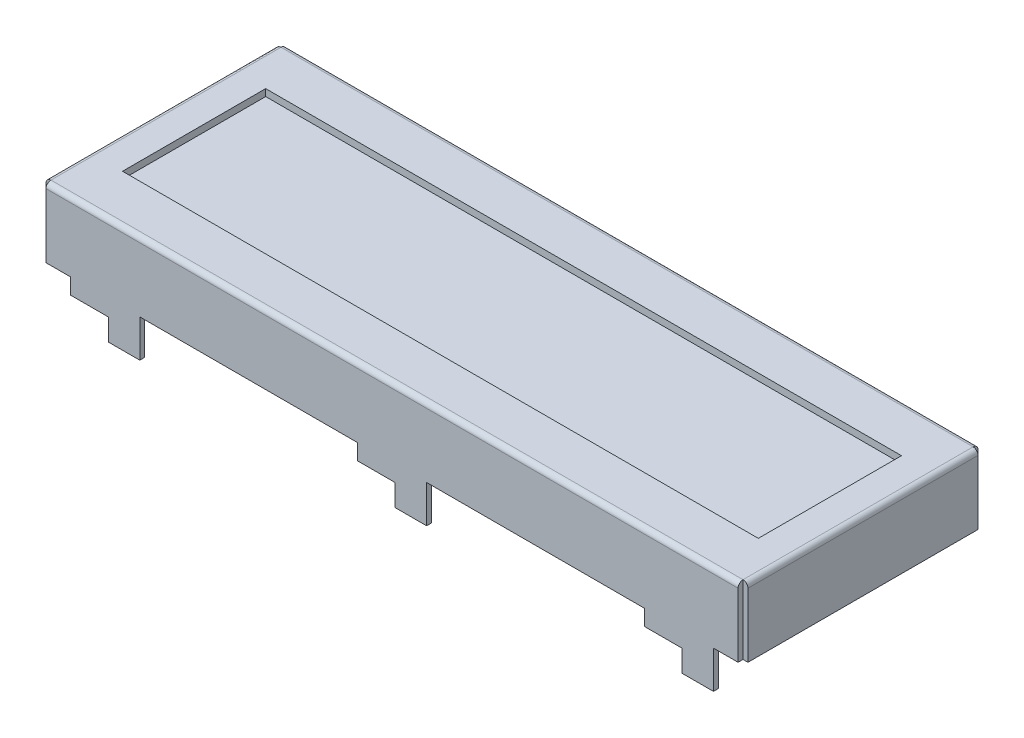
from build123d import *

# Parameters (mm, degrees)
ESQUISSE1_W             = 71.1
ESQUISSE1_H             = 24.3
BOSS_EXTRU_1_DEPTH      = 7
CONG_1_R                = 0.5
ESQUISSE2_W             = 1.653567917
ESQUISSE2_H             = 1.375254205
ESQUISSE2_W_2           = 1.332598991
ESQUISSE2_H_2           = 1.640495544
ESQUISSE2_W_3           = 1.790407611
ESQUISSE2_H_3           = 2.285395674
ENL_V_MAT_EXTRU_1_DEPTH = 7
ESQUISSE3_W             = 64.4
ESQUISSE3_H             = 14.5
ENL_V_MAT_EXTRU_2_DEPTH = 0.7
ESQUISSE4_W             = 7
ESQUISSE4_H             = 0.5
BOSS_EXTRU_2_DEPTH      = 1.6
BOSS_EXTRU_3_DEPTH      = 2.2


with BuildPart() as part:
    # Esquisse1 → Boss.-Extru.1 (new body)
    with BuildSketch(Plane(origin=(0, 0, 0), x_dir=(1, 0, 0), z_dir=(0, 1, 0))):
        with Locations((35.55, 12.15)):
            Rectangle(ESQUISSE1_W, ESQUISSE1_H)
    extrude(amount=BOSS_EXTRU_1_DEPTH)

    # Congé1
    cong_1_edges = [part.edges().sort_by_distance(p)[0] for p in [
        (71.1, 7, -12.15),
        (35.55, 7, -24.3),
        (0, 7, -12.15),
        (35.55, 7, 0),
    ]]
    fillet(cong_1_edges, radius=CONG_1_R)

    # Esquisse2 → Enlèv. mat.-Extru.1 (cut)
    with BuildSketch(Plane(origin=(0, 7, 0), x_dir=(1, 0, 0), z_dir=(0, 1, 0))):
        with Locations((-0.326783959, 24.487627102)):
            Rectangle(ESQUISSE2_W, ESQUISSE2_H)
        with Locations((-0.166299496, -0.320247772)):
            Rectangle(ESQUISSE2_W_2, ESQUISSE2_H_2)
        with Locations((71.495203806, -0.320247772)):
            Rectangle(ESQUISSE2_W_3, ESQUISSE2_H_2)
        with Locations((71.495203806, 24.942697837)):
            Rectangle(ESQUISSE2_W_3, ESQUISSE2_H_3)
    extrude(amount=-ENL_V_MAT_EXTRU_1_DEPTH, mode=Mode.SUBTRACT)

    # Esquisse3 → Enlèv. mat.-Extru.2 (cut)
    with BuildSketch(Plane(origin=(0, 7, 0), x_dir=(1, 0, 0), z_dir=(0, 1, 0))):
        with Locations((35.55, 12.15)):
            Rectangle(ESQUISSE3_W, ESQUISSE3_H)
    extrude(amount=-ENL_V_MAT_EXTRU_2_DEPTH, mode=Mode.SUBTRACT)

    # Esquisse4 → Boss.-Extru.2 (add)
    with BuildSketch(Plane(origin=(0, 0, 0), x_dir=(-1, 0, 0), z_dir=(0, -1, 0))):
        with Locations((-6.5, 0.25)):
            Rectangle(ESQUISSE4_W, ESQUISSE4_H)
        with Locations((-6.5, 24.05)):
            Rectangle(ESQUISSE4_W, ESQUISSE4_H)
        with Locations((-35.55, 0.25)):
            Rectangle(ESQUISSE4_W, ESQUISSE4_H)
        with Locations((-35.55, 24.05)):
            Rectangle(ESQUISSE4_W, ESQUISSE4_H)
        with Locations((-64.6, 0.25)):
            Rectangle(ESQUISSE4_W, ESQUISSE4_H)
        with Locations((-64.6, 24.05)):
            Rectangle(ESQUISSE4_W, ESQUISSE4_H)
    extrude(amount=BOSS_EXTRU_2_DEPTH)

    # Esquisse5 → Boss.-Extru.3 (add)
    with BuildSketch(Plane.XZ.offset(1.6)):
        Polygon((4.385314947, -3.562636494), (4.731995615, -3.8), (6.991422348, -0.5), (10, -0.5), (10, 0), (6.824562261, 0), align=None)
        Polygon((33.435314947, -3.562636494), (33.781995615, -3.8), (36.041422348, -0.5), (39.05, -0.5), (39.05, 0), (35.874562261, 0), align=None)
        Polygon((65.091422348, -0.5), (64.582224877, -0.5), (62.485314947, -3.562636494), (62.831995615, -3.8), align=None)
        Polygon((68.1, -0.5), (68.1, 0), (64.924562261, 0), (64.582224877, -0.5), (65.091422348, -0.5), align=None)
        Polygon((66.714685053, -20.737363506), (66.368004385, -20.5), (64.108577652, -23.8), (61.1, -23.8), (61.1, -24.3), (64.275437739, -24.3), align=None)
        Polygon((8.614685053, -20.737363506), (8.268004385, -20.5), (6.008577652, -23.8), (3, -23.8), (3, -24.3), (6.175437739, -24.3), align=None)
        Polygon((37.664685053, -20.737363506), (37.318004385, -20.5), (35.058577652, -23.8), (32.05, -23.8), (32.05, -24.3), (35.225437739, -24.3), align=None)
    extrude(amount=BOSS_EXTRU_3_DEPTH)


solid = part.part
